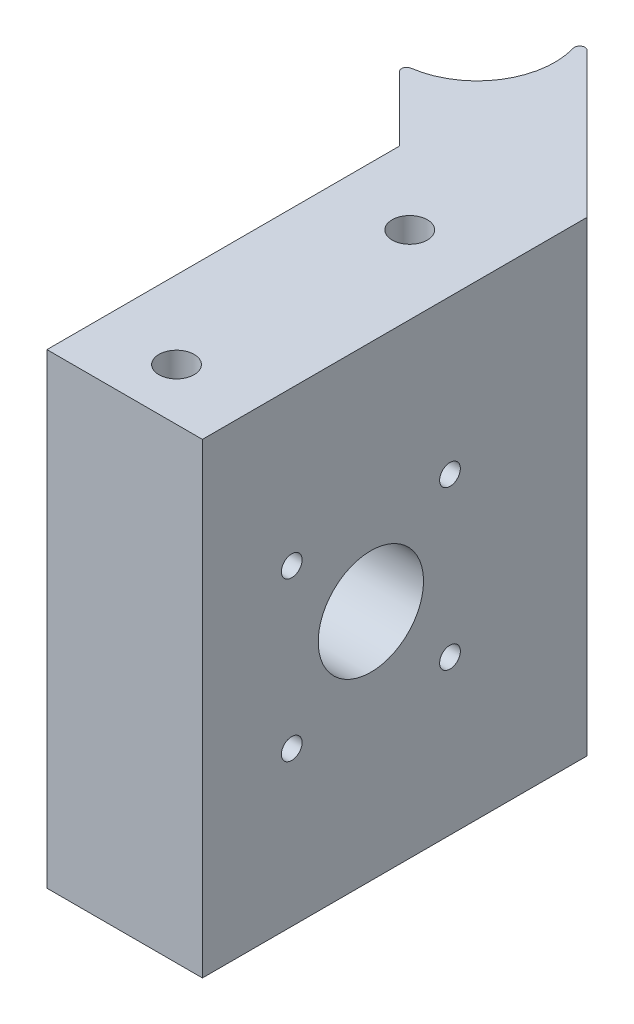
from build123d import *

# Parameters (mm, degrees)
SKETCH1_R           = 1.7
BOSS_EXTRUDE1_DEPTH = 45
CUT_EXTRUDE1_REACH  = 71.934
SKETCH2_R           = 5.0800000000000045
SKETCH2_R_2         = 1.0000000000000009
SKETCH2_R_3         = 1.0000000000000018
FILLET1_R           = 0.5
CUT_EXTRUDE2_DEPTH  = 2
CUT_EXTRUDE3_START  = 17
CUT_EXTRUDE3_DEPTH  = 2


with BuildPart() as part:
    # Sketch1 → Boss-Extrude1 (new body)
    with BuildSketch(Plane(origin=(0, 0, 0), x_dir=(1, 0, 0), z_dir=(0, 1, 0))):
        with BuildLine():
            Line((-7.499999999999999, -5.000000000000001), (7.500000000000001, -4.999999999999999))
            Line((7.500000000000001, -5), (7.499999999999998, 32.10660171779804))
            Line((7.499999999999998, 32.10660171779804), (-9.196699141100867, 48.80330085889908))
            ThreePointArc((-9.196699141100867, 48.80330085889908), (-7.57090350616536, 40.62987425726181), (-14.499999999999998, 36))
            Line((-14.499999999999998, 36), (-7.5, 28.999999999999925))
            Line((-7.5, 28.99999999999993), (-7.499999999999999, -5.000000000000001))
        make_face()
        Circle(SKETCH1_R, mode=Mode.SUBTRACT)
        with Locations((0, 22.5)):
            Circle(SKETCH1_R, mode=Mode.SUBTRACT)
    extrude(amount=BOSS_EXTRUDE1_DEPTH)

    # Sketch2 → Cut-Extrude1 (cut, up to next)
    with BuildSketch(Plane(origin=(7.5, 0, -8.8e-16), x_dir=(-1.2e-16, 0, -1), z_dir=(1, 0, -1.2e-16)), mode=Mode.PRIVATE) as cut_extrude1_sk1:
        with Locations((11.25, 22.5)):
            Circle(SKETCH2_R)
    cut_extrude1_tool1 = extrude(cut_extrude1_sk1.sketch, amount=-CUT_EXTRUDE1_REACH, mode=Mode.PRIVATE) & part.part
    # Sketch2 → Cut-Extrude1 (cut, up to next)
    with BuildSketch(Plane(origin=(7.5, 0, -8.8e-16), x_dir=(-1.2e-16, 0, -1), z_dir=(1, 0, -1.2e-16)), mode=Mode.PRIVATE) as cut_extrude1_sk2:
        with Locations((3.616999999999997, 30.133)):
            Circle(SKETCH2_R_2)
    cut_extrude1_tool2 = extrude(cut_extrude1_sk2.sketch, amount=-CUT_EXTRUDE1_REACH, mode=Mode.PRIVATE) & part.part
    # Sketch2 → Cut-Extrude1 (cut, up to next)
    with BuildSketch(Plane(origin=(7.5, 0, -8.8e-16), x_dir=(-1.2e-16, 0, -1), z_dir=(1, 0, -1.2e-16)), mode=Mode.PRIVATE) as cut_extrude1_sk3:
        with Locations((18.882999999999996, 30.133)):
            Circle(SKETCH2_R_3)
    cut_extrude1_tool3 = extrude(cut_extrude1_sk3.sketch, amount=-CUT_EXTRUDE1_REACH, mode=Mode.PRIVATE) & part.part
    # Sketch2 → Cut-Extrude1 (cut, up to next)
    with BuildSketch(Plane(origin=(7.5, 0, -8.8e-16), x_dir=(-1.2e-16, 0, -1), z_dir=(1, 0, -1.2e-16)), mode=Mode.PRIVATE) as cut_extrude1_sk4:
        with Locations((18.883, 14.867)):
            Circle(SKETCH2_R_3)
    cut_extrude1_tool4 = extrude(cut_extrude1_sk4.sketch, amount=-CUT_EXTRUDE1_REACH, mode=Mode.PRIVATE) & part.part
    # Sketch2 → Cut-Extrude1 (cut, up to next)
    with BuildSketch(Plane(origin=(7.5, 0, -8.8e-16), x_dir=(-1.2e-16, 0, -1), z_dir=(1, 0, -1.2e-16)), mode=Mode.PRIVATE) as cut_extrude1_sk5:
        with Locations((3.6169999999999987, 14.867)):
            Circle(SKETCH2_R_2)
    cut_extrude1_tool5 = extrude(cut_extrude1_sk5.sketch, amount=-CUT_EXTRUDE1_REACH, mode=Mode.PRIVATE) & part.part
    add(cut_extrude1_tool1.solids().sort_by_distance((7.5, 22.5, -11.25))[0], mode=Mode.SUBTRACT)
    add(cut_extrude1_tool2.solids().sort_by_distance((7.5, 30.133, -3.617))[0], mode=Mode.SUBTRACT)
    add(cut_extrude1_tool3.solids().sort_by_distance((7.5, 30.133, -18.883))[0], mode=Mode.SUBTRACT)
    add(cut_extrude1_tool4.solids().sort_by_distance((7.5, 14.867, -18.883))[0], mode=Mode.SUBTRACT)
    add(cut_extrude1_tool5.solids().sort_by_distance((7.5, 14.867, -3.617))[0], mode=Mode.SUBTRACT)

    # Fillet1
    fillet1_edges = [part.edges().sort_by_distance(p)[0] for p in [
        (-9.196699141100865, 22.5, -48.80330085889908),
        (-14.499999999999998, 22.5, -36),
    ]]
    fillet(fillet1_edges, radius=FILLET1_R)

    # Sketch3 → Cut-Extrude2 (cut, symmetric)
    with BuildSketch(Plane(origin=(0, 22.5, 0), x_dir=(1, 0, 0), z_dir=(0, 1, 0))):
        with BuildLine():
            Line((-8.136038969321103, 37.136038969321035), (-2.832738110421976, 42.43933982822012))
            Line((-2.832738110421976, 42.43933982822012), (-1.7720779386421608, 41.37867965644029))
            Line((-1.7720779386421608, 41.37867965644029), (-7.075378797541292, 36.07537879754122))
            ThreePointArc((-7.075378797541292, 36.07537879754122), (-9.276718417433415, 34.39135962345529), (-11.841997191011883, 33.34199719101184))
            Line((-11.841997191011883, 33.34199719101184), (-13.108259049699228, 34.608259049699214))
            ThreePointArc((-13.108259049699228, 34.608259049699214), (-10.42137938330202, 35.47722904072127), (-8.136038969321103, 37.136038969321035))
        make_face()
    extrude(amount=CUT_EXTRUDE2_DEPTH, both=True, mode=Mode.SUBTRACT)

    # Sketch3_2 → Cut-Extrude3 (cut, symmetric)
    with BuildSketch(Plane(origin=(0, 22.5, 0), x_dir=(1, 0, 0), z_dir=(0, 1, 0)).offset(CUT_EXTRUDE3_START)):
        with BuildLine():
            Line((-8.136038969321103, 37.136038969321035), (-2.832738110421976, 42.43933982822012))
            Line((-2.832738110421976, 42.43933982822012), (-1.7720779386421608, 41.37867965644029))
            Line((-1.7720779386421608, 41.37867965644029), (-7.075378797541292, 36.07537879754122))
            ThreePointArc((-7.075378797541292, 36.07537879754122), (-9.276718417433415, 34.39135962345529), (-11.841997191011883, 33.34199719101184))
            Line((-11.841997191011883, 33.34199719101184), (-13.108259049699228, 34.608259049699214))
            ThreePointArc((-13.108259049699228, 34.608259049699214), (-10.42137938330202, 35.47722904072127), (-8.136038969321103, 37.136038969321035))
        make_face()
    cut_extrude3 = extrude(amount=CUT_EXTRUDE3_DEPTH, both=True, mode=Mode.SUBTRACT)

    # Mirror1: Cut-Extrude3 across plane
    add(cut_extrude3.mirror(Plane.ZX.offset(22.5)), mode=Mode.SUBTRACT)


solid = part.part
